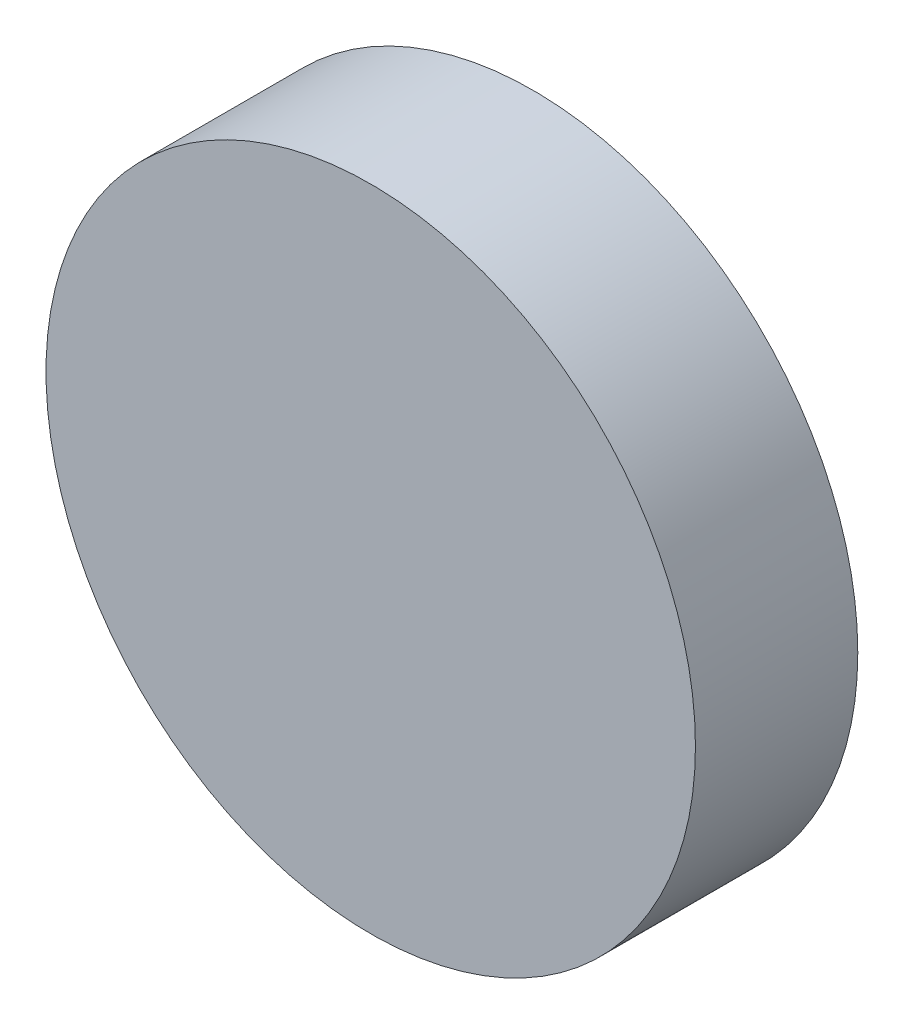
from build123d import *

# Parameters (mm, degrees)
SKETCH1_R           = 63.5
BOSS_EXTRUDE1_DEPTH = 31.75
SKETCH2_R           = 57.15
SKETCH2_R_2         = 55.5625
CUT_EXTRUDE1_DEPTH  = 3.175


with BuildPart() as part:
    # Sketch1 → Boss-Extrude1 (new body)
    with BuildSketch(Plane.XY):
        Circle(SKETCH1_R)
    extrude(amount=BOSS_EXTRUDE1_DEPTH)

    # Sketch2 → Cut-Extrude1 (cut)
    with BuildSketch(Plane(origin=(0, 0, 0), x_dir=(-1, 0, 0), z_dir=(0, 0, -1))):
        Circle(SKETCH2_R)
        Circle(SKETCH2_R_2, mode=Mode.SUBTRACT)
    extrude(amount=-CUT_EXTRUDE1_DEPTH, mode=Mode.SUBTRACT)


solid = part.part
